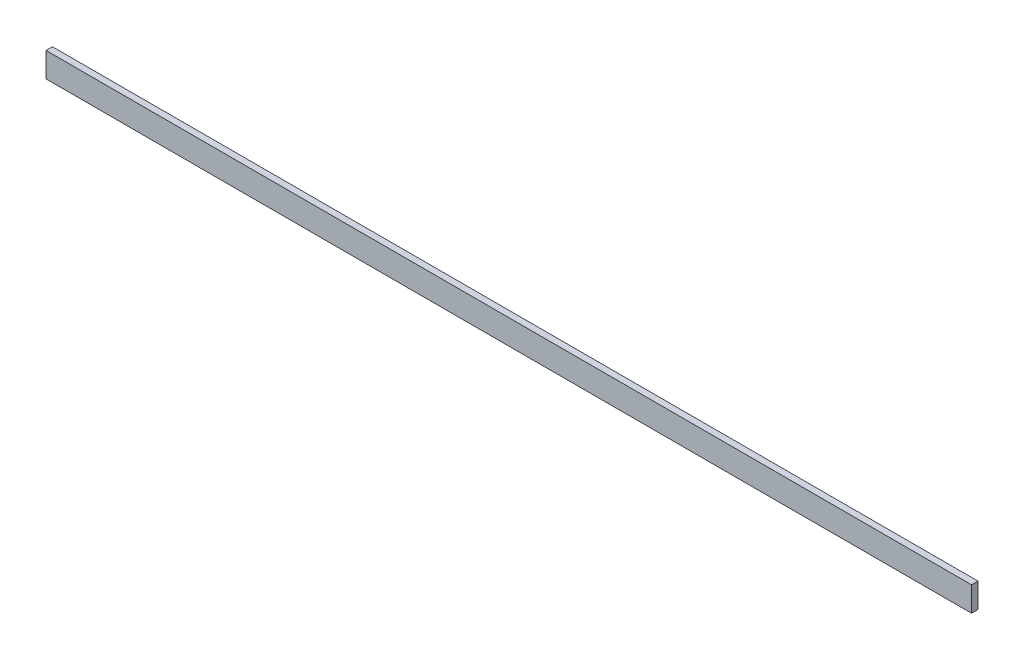
from build123d import *

# Parameters (mm, degrees)
SKETCH1_W           = 1437.249750812
SKETCH1_H           = 38.292622135
BOSS_EXTRUDE1_DEPTH = 10


with BuildPart() as part:
    # Sketch1 → Boss-Extrude1 (new body)
    with BuildSketch(Plane.XY):
        with Locations((718.624875406, 19.146311068)):
            Rectangle(SKETCH1_W, SKETCH1_H)
    extrude(amount=BOSS_EXTRUDE1_DEPTH)


solid = part.part
